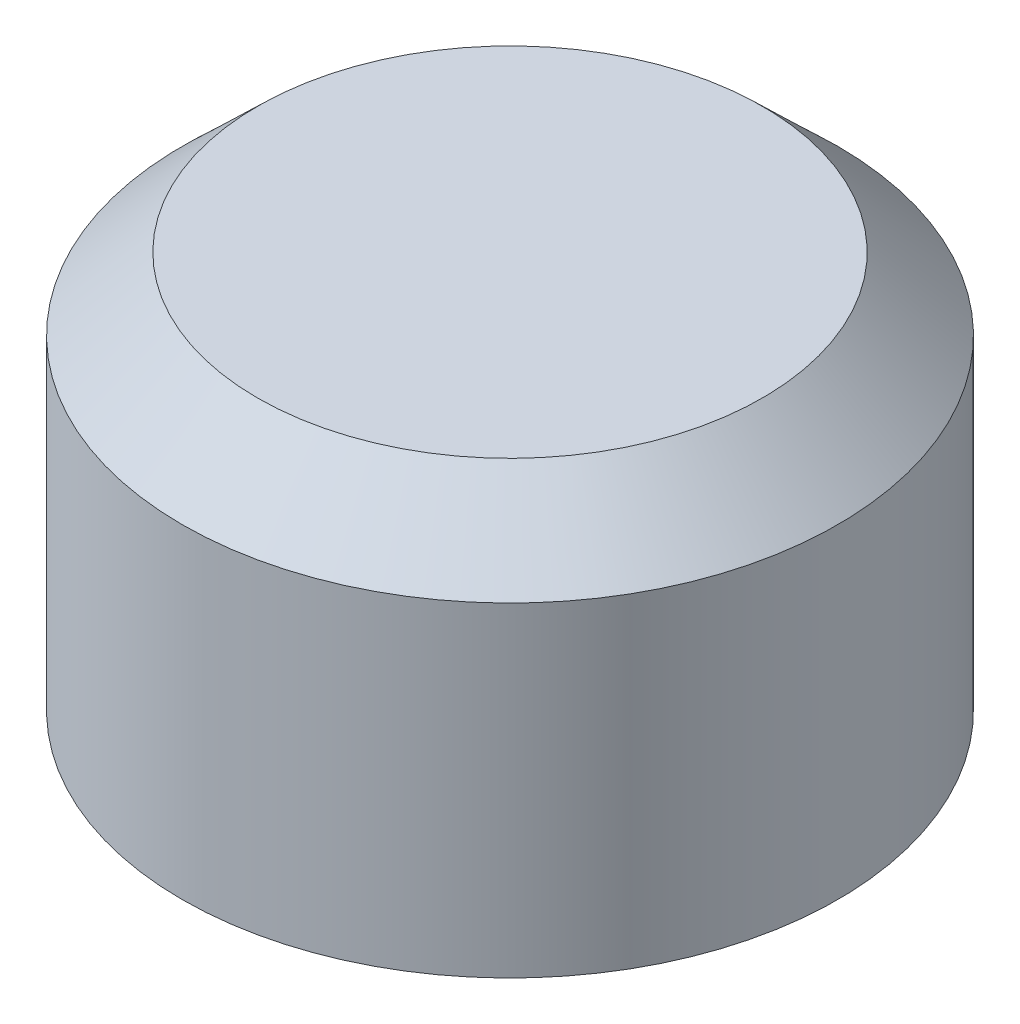
from build123d import *


with BuildPart() as part:
    # Sketch1 → Revolve1 (revolve)
    with BuildSketch(Plane.XY):
        Polygon((-2438.4, 0), (-2438.4, 2753.721024484), (-2118.721024484, 3073.4), (-1190.8772065, 3073.4), (-914.4, 2796.9227935), (-914.4, 2074), (-364.14040468, 1523.74040468), (-389.54040468, 1523.74040468), (-939.8, 2074), (-939.8, 2786.401769016), (-1201.398230984, 3048), (-2108.2, 3048), (-2413, 2743.2), (-2413, 0), align=None)
    revolve(axis=Axis((0, 3520.44, 0), (0, -1, 0)))


with BuildPart() as body_2:
    # Sketch2 → Revolve2 (revolve)
    with BuildSketch(Plane.XY):
        Polygon((-2743.2, 0), (-2768.6, 0), (-2768.6, 2743.2), (-2133.6, 3352.8), (0, 3352.8), (0, 3327.4), (-2123.381318695, 3327.4), (-2743.2, 2732.374065947), align=None)
    revolve(axis=Axis((0, 3520.44, 0), (0, -1, 0)))


solid = Compound([part.part, body_2.part])
